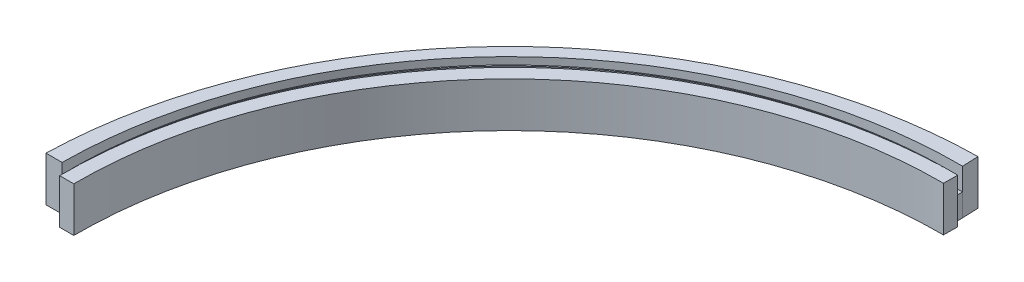
from build123d import *

# Parameters (mm, degrees)
SKETCH1_W          = 2.06
SKETCH1_H          = 6.53
SKETCH3_W          = 1.5
SKETCH3_H          = 6.53
SKETCH6_W          = 2.34
SKETCH6_H          = 6.53
CUT_EXTRUDE1_DEPTH = 3.25
SCALE1_SCALE       = 0.5


with BuildPart() as part:
    # Sweep1: sweep along a path in Sketch2
    with BuildLine(Plane(origin=(0, 0, 0), x_dir=(1, 0, 0), z_dir=(0, 1, 0))) as sweep1_path:
        ThreePointArc((2.06, 0), (20.505721927, 44.951087367), (65.415754098, 63.496542965))
    # Sketch1 → Sweep1 (sweep)
    with BuildSketch(Plane.XY):
        with Locations((1.03, 3.265)):
            Rectangle(SKETCH1_W, SKETCH1_H)
    sweep(path=sweep1_path.line)

    # Sweep2: sweep along a path in Sketch4
    with BuildLine(Plane(origin=(0, 0, 0), x_dir=(1, 0, 0), z_dir=(0, 1, 0))) as sweep2_path:
        ThreePointArc((-2.34, 1.85), (17.612800495, 48.600532533), (64.642950035, 67.885023038))
    # Sketch3 → Sweep2 (sweep)
    with BuildSketch(Plane.XY.offset(-1.85)):
        with Locations((-0.75, 3.265)):
            Rectangle(SKETCH3_W, SKETCH3_H)
    sweep(path=sweep2_path.line)

    # Sweep3: sweep along a path in Sketch7
    with BuildLine(Plane(origin=(0, 6.53, 0), x_dir=(1, 0, 0), z_dir=(0, 1, 0))) as sweep3_path:
        ThreePointArc((-1.5, 1.85), (18.444326424, 47.774036761), (64.654921624, 67.045108351))
    # Sketch6 → Sweep3 (sweep)
    with BuildSketch(Plane.XY.offset(-1.85)):
        with Locations((-2.67, 3.265)):
            Rectangle(SKETCH6_W, SKETCH6_H)
    sweep(path=sweep3_path.line)

    # Sketch8 → Cut-Extrude1 (cut)
    with BuildSketch(Plane(origin=(0, 6.53, 0), x_dir=(1, 0, 0), z_dir=(0, 1, 0))):
        with BuildLine():
            Line((0, 1.85), (-1.4905859, 1.85))
            ThreePointArc((-1.4905859, 1.85), (18.079818822, 48.146737329), (64.654921624, 67.045108351))
            Line((64.654921624, 67.045108351), (64.676165293, 65.554673837))
            ThreePointArc((64.676165293, 65.554673837), (19.144412702, 47.097209332), (0, 1.85))
        make_face()
    extrude(amount=-CUT_EXTRUDE1_DEPTH, mode=Mode.SUBTRACT)


with BuildPart() as part_1:
    # Scale1: scaled about (23.281504141, 3.019990998, -42.576303798)
    add(part.part.scale(SCALE1_SCALE).moved(Location((11.64075207, 1.509995499, -21.288151899))))


solid = part_1.part
